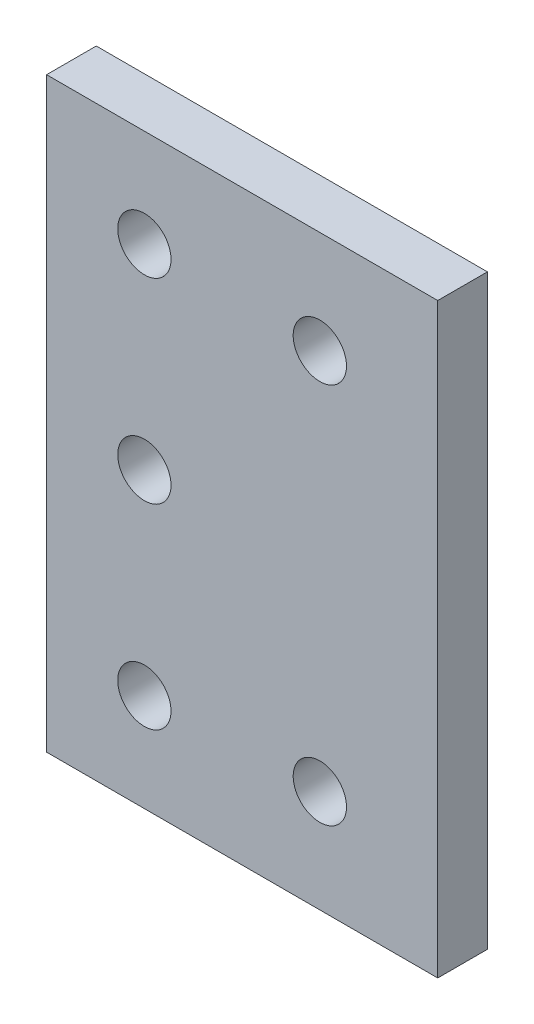
from build123d import *

# Parameters (mm, degrees)
SKETCH1_W           = 50
SKETCH1_H           = 75
BOSS_EXTRUDE1_DEPTH = 6.35
SKETCH2_R           = 3.405
CUT_EXTRUDE1_DEPTH  = 7.35


with BuildPart() as part:
    # Sketch1 → Boss-Extrude1 (new body)
    with BuildSketch(Plane.XY):
        Rectangle(SKETCH1_W, SKETCH1_H)
    extrude(amount=BOSS_EXTRUDE1_DEPTH)

    # Sketch2 → Cut-Extrude1 (cut, through all)
    with BuildSketch(Plane.XY.offset(6.35)):
        with Locations((-12.5, 25)):
            Circle(SKETCH2_R)
        with Locations((9.929, 24.4)):
            Circle(SKETCH2_R)
        with Locations((-12.5, 0)):
            Circle(SKETCH2_R)
        with Locations((-12.5, -25)):
            Circle(SKETCH2_R)
        with Locations((9.929, -24.4)):
            Circle(SKETCH2_R)
    extrude(amount=-CUT_EXTRUDE1_DEPTH, mode=Mode.SUBTRACT)


solid = part.part
